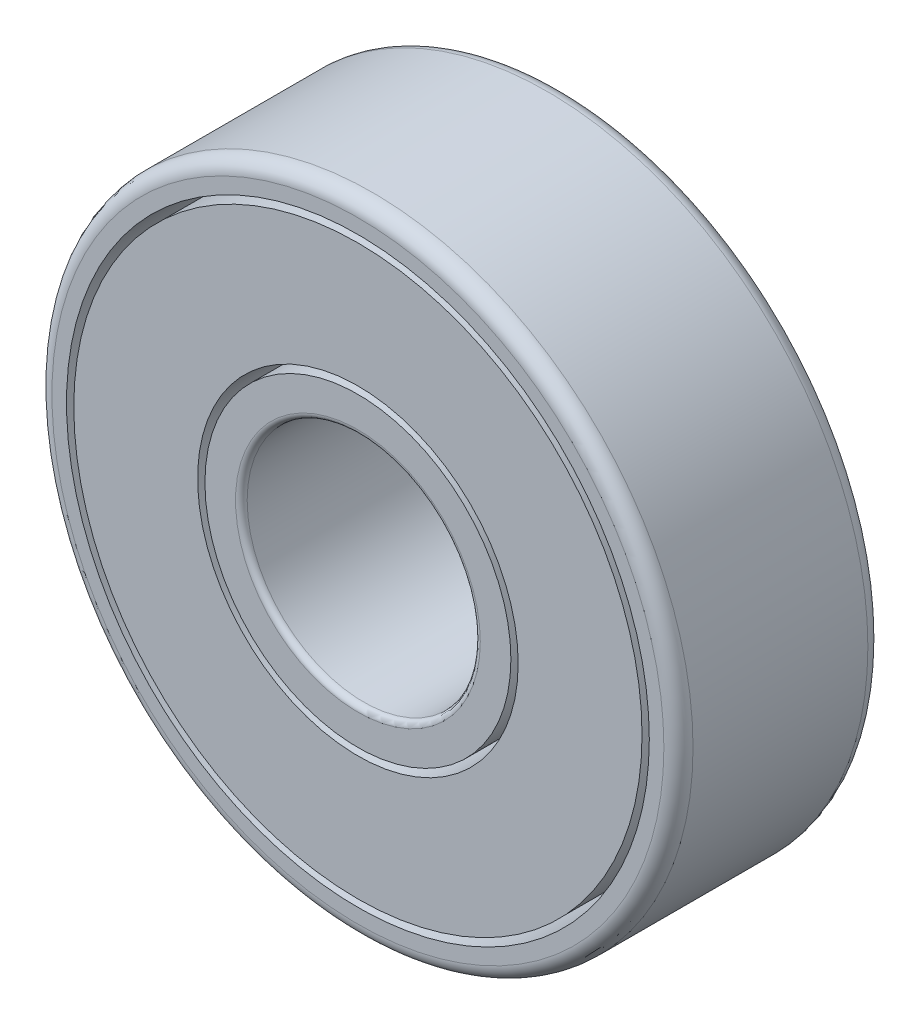
from build123d import *

# Parameters (mm, degrees)
CROQUIS1_R                = 9.75
CROQUIS1_R_2              = 5.5
SALIENTE_EXTRUIR1_DEPTH   = 7
CROQUIS1_R_3              = 5.25
CROQUIS1_R_4              = 4
SALIENTE_EXTRUIR1_2_DEPTH = 7
CROQUIS1_R_5              = 11
CROQUIS1_R_6              = 10
SALIENTE_EXTRUIR1_3_DEPTH = 7
REDONDEO1_R               = 0.2
REDONDEO2_R               = 0.5


with BuildPart() as part:
    # Croquis1 → Saliente-Extruir1 (new body)
    with BuildSketch(Plane.XY):
        Circle(CROQUIS1_R)
        Circle(CROQUIS1_R_2, mode=Mode.SUBTRACT)
    extrude(amount=SALIENTE_EXTRUIR1_DEPTH)


with BuildPart() as body_2:
    # Croquis1 → Saliente-Extruir1 2 (new body)
    with BuildSketch(Plane.XY):
        Circle(CROQUIS1_R_3)
        Circle(CROQUIS1_R_4, mode=Mode.SUBTRACT)
    extrude(amount=SALIENTE_EXTRUIR1_2_DEPTH)

    # Redondeo1
    redondeo1_edges = [body_2.edges().sort_by_distance(p)[0] for p in [
        (-4, 0, 0),
        (-4, 0, 7),
    ]]
    fillet(redondeo1_edges, radius=REDONDEO1_R)


with BuildPart() as body_3:
    # Croquis1 → Saliente-Extruir1 3 (new body)
    with BuildSketch(Plane.XY):
        Circle(CROQUIS1_R_5)
        Circle(CROQUIS1_R_6, mode=Mode.SUBTRACT)
    extrude(amount=SALIENTE_EXTRUIR1_3_DEPTH)

    # Redondeo2
    redondeo2_edges = [body_3.edges().sort_by_distance(p)[0] for p in [
        (-11, 0, 7),
        (-11, 0, 0),
    ]]
    fillet(redondeo2_edges, radius=REDONDEO2_R)


solid = Compound([part.part, body_2.part, body_3.part])
